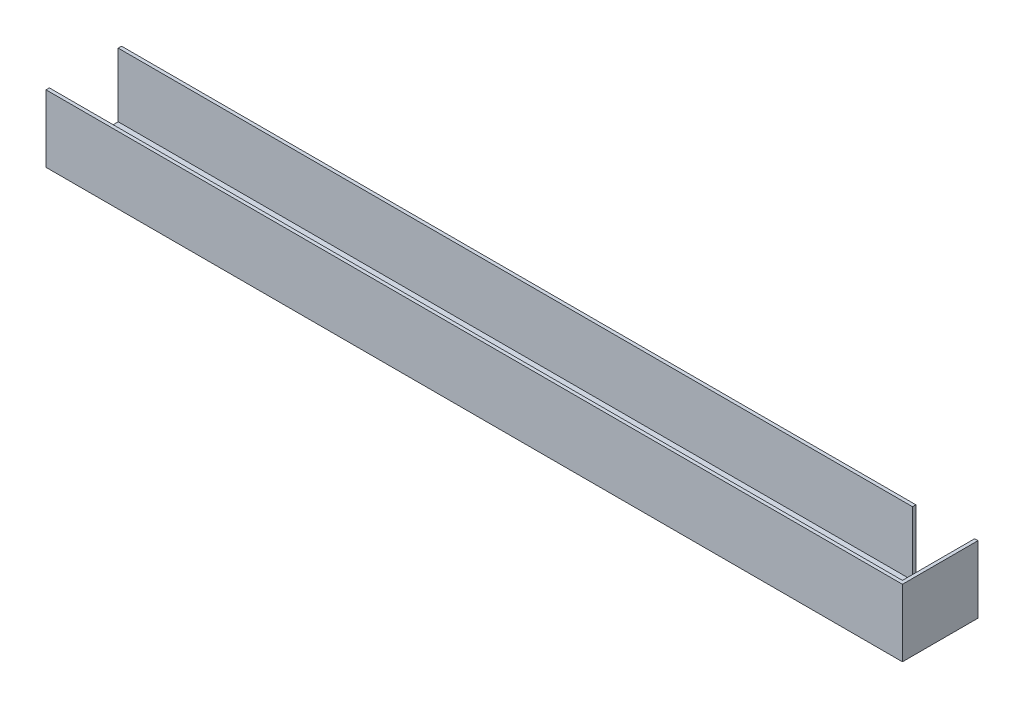
from build123d import *

# Parameters (mm, degrees)
SKETCH1_W           = 1295.4
SKETCH1_H           = 101.6
BOSS_EXTRUDE1_DEPTH = 114.3
SHELL1_T            = -5.08
SKETCH3_W           = 88.9
SKETCH3_H           = 96.52
CUT_EXTRUDE1_DEPTH  = 5.08


with BuildPart() as part:
    # Sketch1 → Boss-Extrude1 (new body)
    with BuildSketch(Plane.XY):
        with Locations((0, 50.8)):
            Rectangle(SKETCH1_W, SKETCH1_H)
    extrude(amount=-BOSS_EXTRUDE1_DEPTH)

    # Shell1
    shell1_openings = [part.faces().sort_by_distance(p)[0] for p in [
        (-647.7, 50.8, -57.15),
        (0, 101.6, -57.15),
    ]]
    offset(amount=SHELL1_T, openings=shell1_openings, kind=Kind.INTERSECTION)

    # Sketch3 → Cut-Extrude1 (cut)
    with BuildSketch(Plane(origin=(0, 0, -114.3), x_dir=(-1, 0, 0), z_dir=(0, 0, -1))):
        with Locations((-598.17, 53.34)):
            Rectangle(SKETCH3_W, SKETCH3_H)
    extrude(amount=-CUT_EXTRUDE1_DEPTH, mode=Mode.SUBTRACT)


solid = part.part
